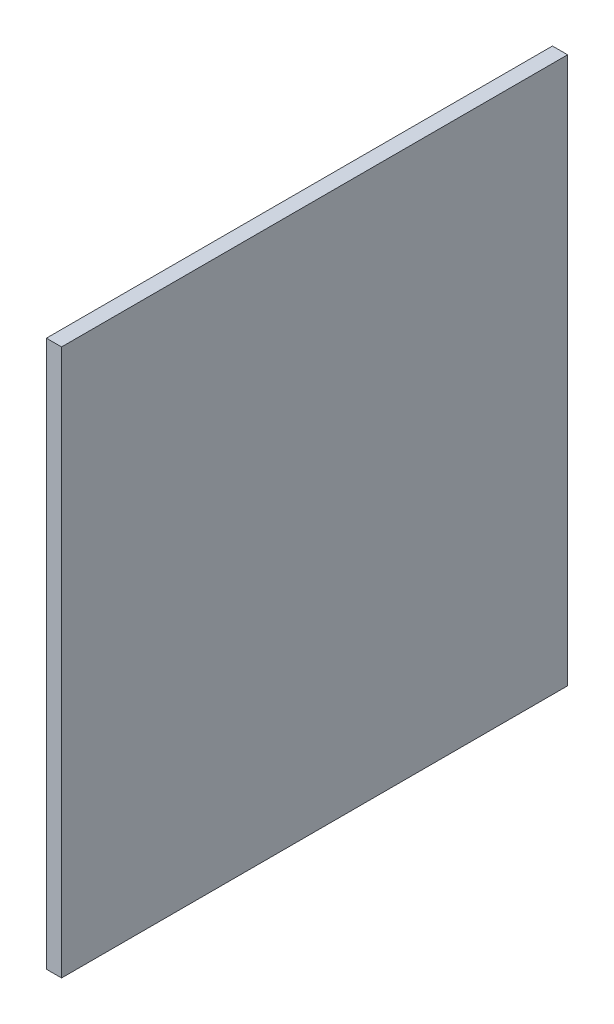
from build123d import *

# Parameters (mm, degrees)
SKETCH1_W           = 1.5
SKETCH1_H           = 50
BOSS_EXTRUDE1_DEPTH = 27


with BuildPart() as part:
    # Sketch1 → Boss-Extrude1 (new body, symmetric)
    with BuildSketch(Plane(origin=(0, 0, 0), x_dir=(1, 0, 0), z_dir=(0, 1, 0))):
        Rectangle(SKETCH1_W, SKETCH1_H)
    extrude(amount=BOSS_EXTRUDE1_DEPTH, both=True)


solid = part.part
